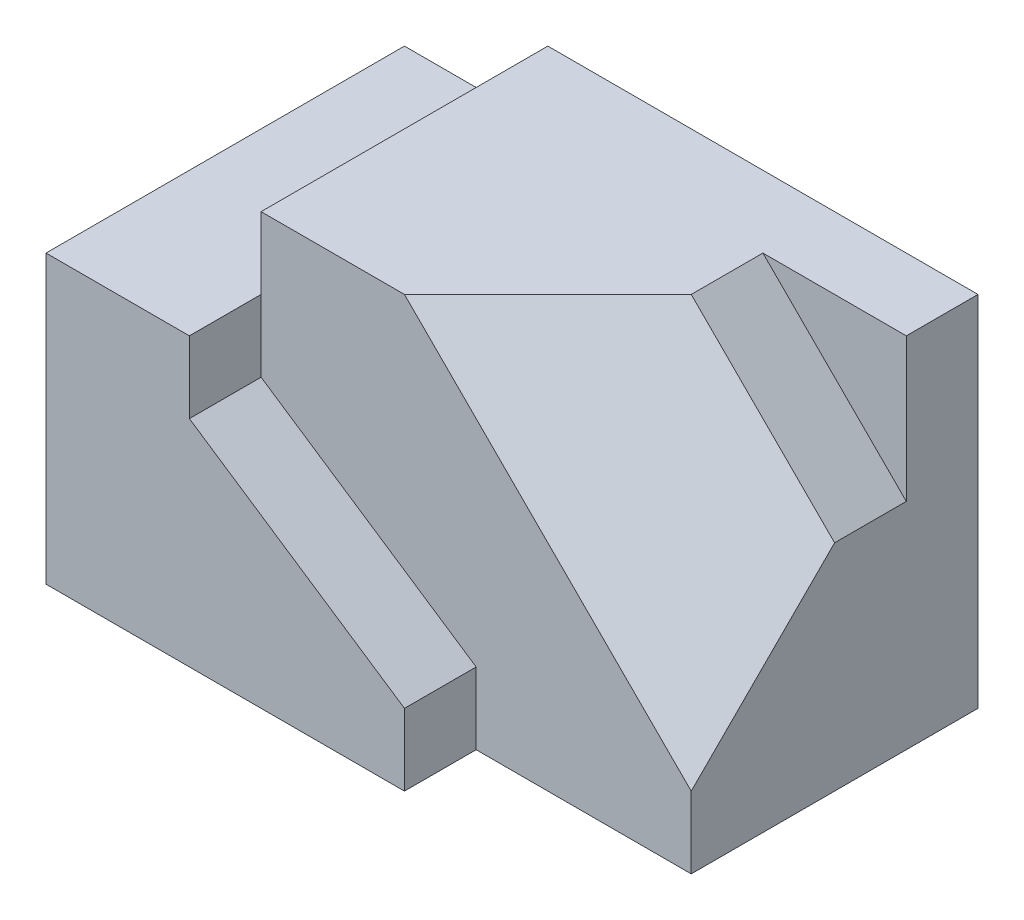
from build123d import *

# Parameters (mm, degrees)
SKETCH2_W           = 80
SKETCH2_H           = 50
BOSS_EXTRUDE1_DEPTH = 10
SKETCH3_W           = 30
SKETCH3_H           = 10
CUT_EXTRUDE1_DEPTH  = 10
SKETCH4_W           = 60
SKETCH4_H           = 40
BOSS_EXTRUDE2_DEPTH = 40
BOSS_EXTRUDE3_DEPTH = 50
CUT_EXTRUDE2_DEPTH  = 50
CUT_EXTRUDE3_DEPTH  = 50


with BuildPart() as part:
    # Sketch2 → Boss-Extrude1 (new body)
    with BuildSketch(Plane(origin=(0, 0, 0), x_dir=(1, 0, 0), z_dir=(0, 1, 0))):
        with Locations((40, 25)):
            Rectangle(SKETCH2_W, SKETCH2_H)
    extrude(amount=BOSS_EXTRUDE1_DEPTH)

    # Sketch3 → Cut-Extrude1 (cut)
    with BuildSketch(Plane(origin=(0, 10, 0), x_dir=(1, 0, 0), z_dir=(0, 1, 0))):
        with Locations((65, 5)):
            Rectangle(SKETCH3_W, SKETCH3_H)
    extrude(amount=-CUT_EXTRUDE1_DEPTH, mode=Mode.SUBTRACT)

    # Sketch4 → Boss-Extrude2 (add)
    with BuildSketch(Plane(origin=(0, 10, 0), x_dir=(1, 0, 0), z_dir=(0, 1, 0))):
        with Locations((50, 30)):
            Rectangle(SKETCH4_W, SKETCH4_H)
    extrude(amount=BOSS_EXTRUDE2_DEPTH)

    # Sketch5 → Boss-Extrude3 (add)
    with BuildSketch(Plane.XY):
        Polygon((20, 30), (50, 10), (0, 10), (0, 40), (20, 40), align=None)
    extrude(amount=-BOSS_EXTRUDE3_DEPTH)

    # Sketch6 → Cut-Extrude2 (cut)
    with BuildSketch(Plane.XY.offset(-40)):
        Polygon((60, 50), (80, 30), (80, 50), align=None)
    extrude(amount=CUT_EXTRUDE2_DEPTH, mode=Mode.SUBTRACT)

    # Sketch9 → Cut-Extrude3 (cut)
    with BuildSketch(Plane(origin=(26.666666667, 26.666666667, 26.666666667), x_dir=(-0.816496581, 0.40824829, 0.40824829), z_dir=(-0.577350269, -0.577350269, -0.577350269))):
        Polygon((-16.329931619, 42.426406871), (-40.824829046, 56.568542495), (-65.319726474, 42.426406871), (-65.319726474, 14.142135624), align=None)
    extrude(amount=-CUT_EXTRUDE3_DEPTH, mode=Mode.SUBTRACT)


solid = part.part
